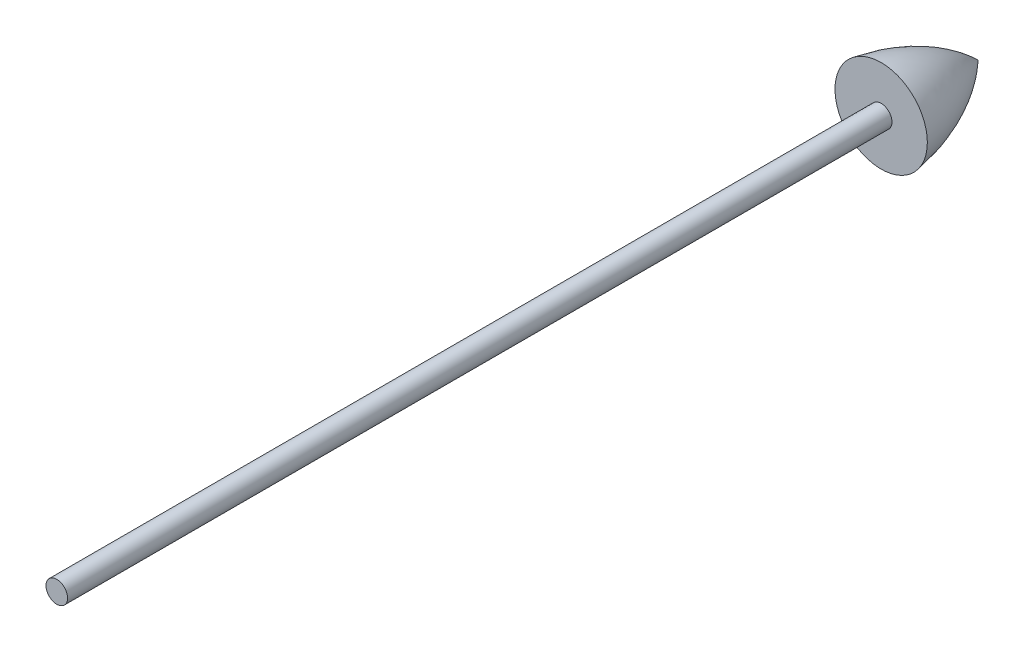
from build123d import *


with BuildPart() as part:
    # Sketch4 → Revolve4 (revolve)
    with BuildSketch(Plane(origin=(0, 0, 0), x_dir=(0, 0, -1), z_dir=(1, 0, 0))):
        with BuildLine():
            Line((1228.290091086, 297.322506275), (1962.317567139, 297.322506275))
            Line((1962.317567139, 297.322506275), (3617.148645535, 297.322506275))
            Line((3617.148645535, 297.322506275), (3633.245395961, 297.322506275))
            Line((3633.245395961, 297.322506275), (3633.245395961, 411.499706435))
            add(Edge.make_bspline(
                [(3633.245395961, 411.499706435), (3821.740640388, 382.092840605), (3945.842996946, 262.437167269)],
                knots=[0, 0, 0, 0.920510374, 0.920510374, 0.920510374], degree=2))
            Line((3945.842996946, 262.437167269), (1158.931681116, 262.437167269))
            Line((1158.931681116, 262.437167269), (971.847033357, 262.437167269))
            Line((971.847033357, 262.437167269), (971.847033357, 297.322506275))
            Line((971.847033357, 297.322506275), (1158.931681116, 297.322506275))
            Line((1158.931681116, 297.322506275), (1228.290091086, 297.322506275))
        make_face()
    revolve(axis=Axis((0, 262.437167269, -1158.931681116), (0, 0, -1)))


solid = part.part
